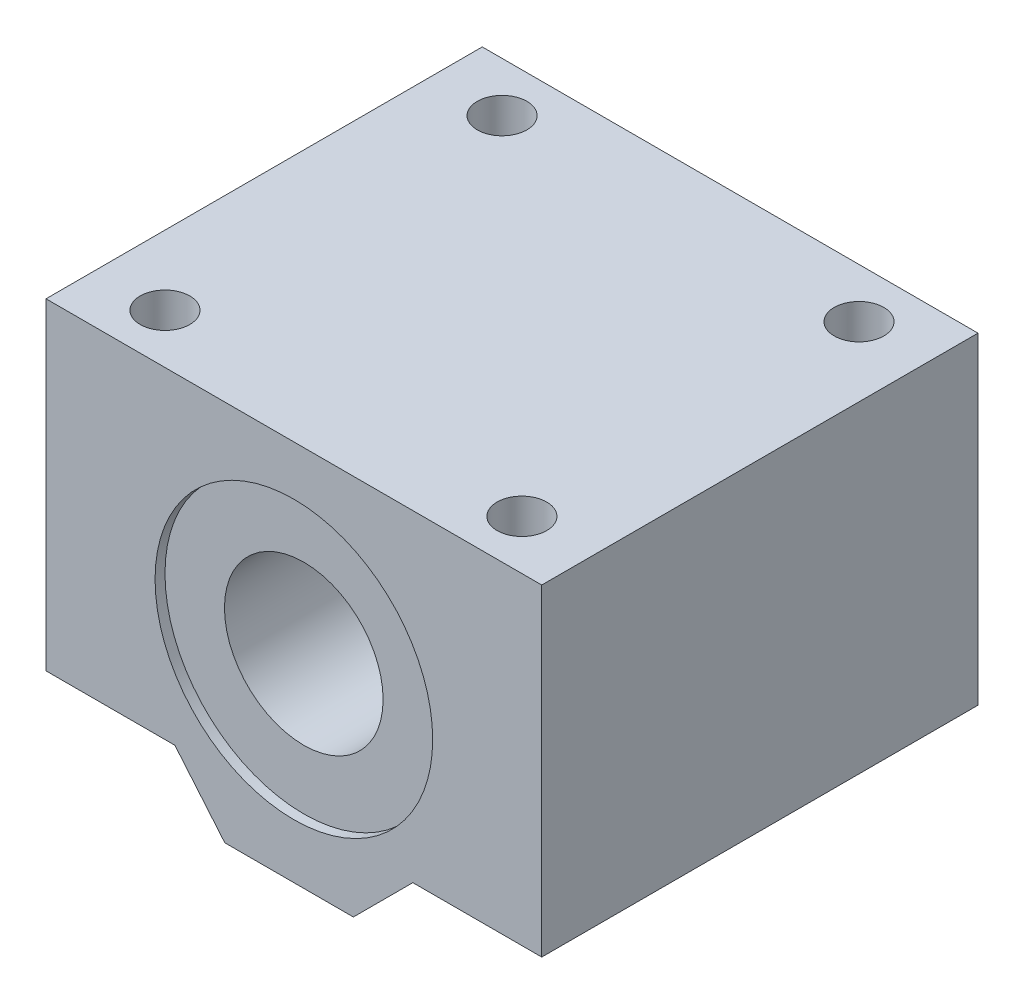
from build123d import *

# Parameters (mm, degrees)
SKETCH1_W           = 50
SKETCH1_H           = 38.5
SKETCH1_R           = 8
BOSS_EXTRUDE1_DEPTH = 22
CUT_EXTRUDE5_DEPTH  = 45
SKETCH2_R           = 2.15
CUT_EXTRUDE1_DEPTH  = 39.5
SKETCH3_R           = 2.5
CUT_EXTRUDE2_DEPTH  = 12
SKETCH4_R           = 14
CUT_EXTRUDE3_DEPTH  = 1
SKETCH5_R           = 14
CUT_EXTRUDE4_DEPTH  = 1


with BuildPart() as part:
    # Sketch1 → Boss-Extrude1 (new body, symmetric)
    with BuildSketch(Plane.XY):
        Rectangle(SKETCH1_W, SKETCH1_H)
        with Locations((0, 0.25)):
            Circle(SKETCH1_R, mode=Mode.SUBTRACT)
    extrude(amount=BOSS_EXTRUDE1_DEPTH, both=True)

    # Sketch6 → Cut-Extrude5 (cut, through all)
    with BuildSketch(Plane.XY.offset(22)):
        Polygon((-25, -13.25), (-12, -13.25), (-6.965402213, -19.25), (-25, -19.25), align=None)
        Polygon((25, -13.25), (12, -13.25), (6, -19.25), (25, -19.25), align=None)
    extrude(amount=-CUT_EXTRUDE5_DEPTH, mode=Mode.SUBTRACT)

    # Sketch2 → Cut-Extrude1 (cut, through all)
    with BuildSketch(Plane(origin=(0, 19.25, 0), x_dir=(-1, 0, 0), z_dir=(0, -1, 0))):
        with Locations((18, -17)):
            Circle(SKETCH2_R)
        with Locations((-18, -17)):
            Circle(SKETCH2_R)
        with Locations((-18, 17)):
            Circle(SKETCH2_R)
        with Locations((18, 17)):
            Circle(SKETCH2_R)
    extrude(amount=CUT_EXTRUDE1_DEPTH, mode=Mode.SUBTRACT)

    # Sketch3 → Cut-Extrude2 (cut)
    with BuildSketch(Plane.XZ.offset(-19.25)):
        with Locations((-18, 17)):
            Circle(SKETCH3_R)
        with Locations((18, 17)):
            Circle(SKETCH3_R)
        with Locations((18, -17)):
            Circle(SKETCH3_R)
        with Locations((-18, -17)):
            Circle(SKETCH3_R)
    extrude(amount=CUT_EXTRUDE2_DEPTH, mode=Mode.SUBTRACT)

    # Sketch4 → Cut-Extrude3 (cut)
    with BuildSketch(Plane.XY.offset(22)):
        with Locations((0, 0.25)):
            Circle(SKETCH4_R)
    extrude(amount=-CUT_EXTRUDE3_DEPTH, mode=Mode.SUBTRACT)

    # Sketch5 → Cut-Extrude4 (cut)
    with BuildSketch(Plane(origin=(0, 0, -22), x_dir=(-1, 0, 0), z_dir=(0, 0, -1))):
        with Locations((0, 0.25)):
            Circle(SKETCH5_R)
    extrude(amount=-CUT_EXTRUDE4_DEPTH, mode=Mode.SUBTRACT)


solid = part.part
